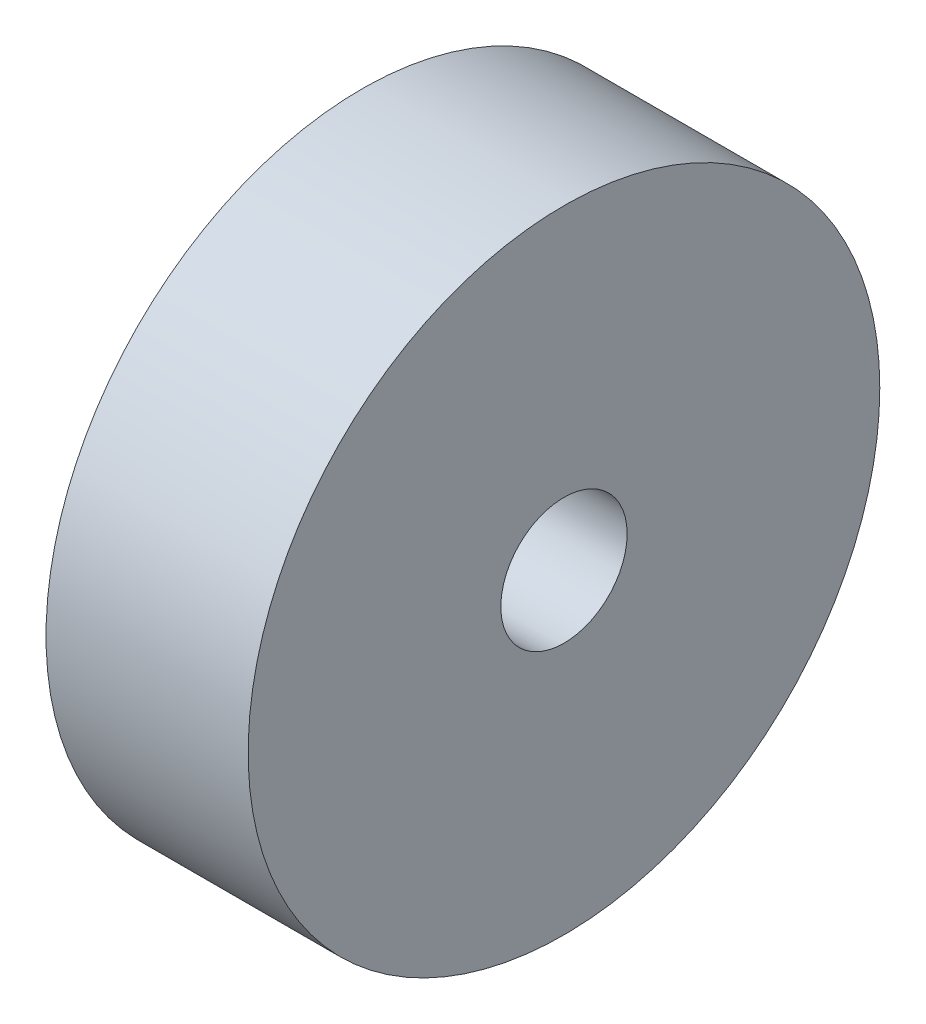
from build123d import *

# Parameters (mm, degrees)
SKETCH2_R           = 12.5
SKETCH2_R_2         = 2.5
BOSS_EXTRUDE1_DEPTH = 8


with BuildPart() as part:
    # Sketch2 → Boss-Extrude1 (new body)
    with BuildSketch(Plane(origin=(0, 0, 0), x_dir=(0, 0, -1), z_dir=(1, 0, 0))):
        Circle(SKETCH2_R)
        Circle(SKETCH2_R_2, mode=Mode.SUBTRACT)
    extrude(amount=BOSS_EXTRUDE1_DEPTH)


solid = part.part
